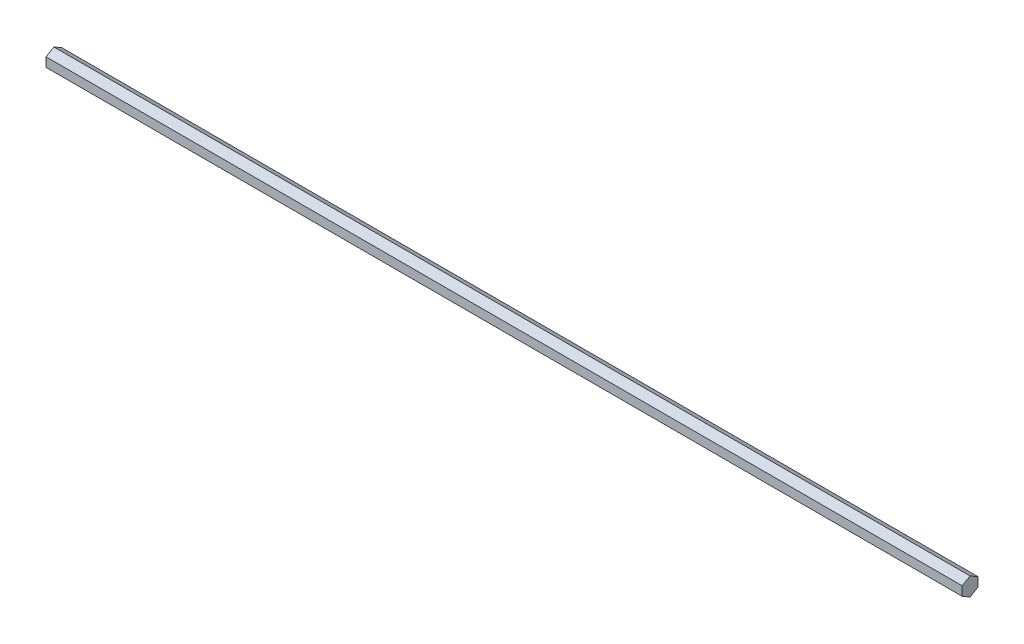
from build123d import *

# Parameters (mm, degrees)
BOSS_EXTRUDE1_DEPTH = 736.6


with BuildPart() as part:
    # Sketch1 → Boss-Extrude1 (new body)
    with BuildSketch(Plane(origin=(0, 0, 0), x_dir=(0, 0, -1), z_dir=(1, 0, 0))):
        Polygon((0, 7.332348419), (-6.35, 3.666174209), (-6.35, -3.666174209), (0, -7.332348419), (6.35, -3.666174209), (6.35, 3.666174209), align=None)
    extrude(amount=BOSS_EXTRUDE1_DEPTH)


solid = part.part
